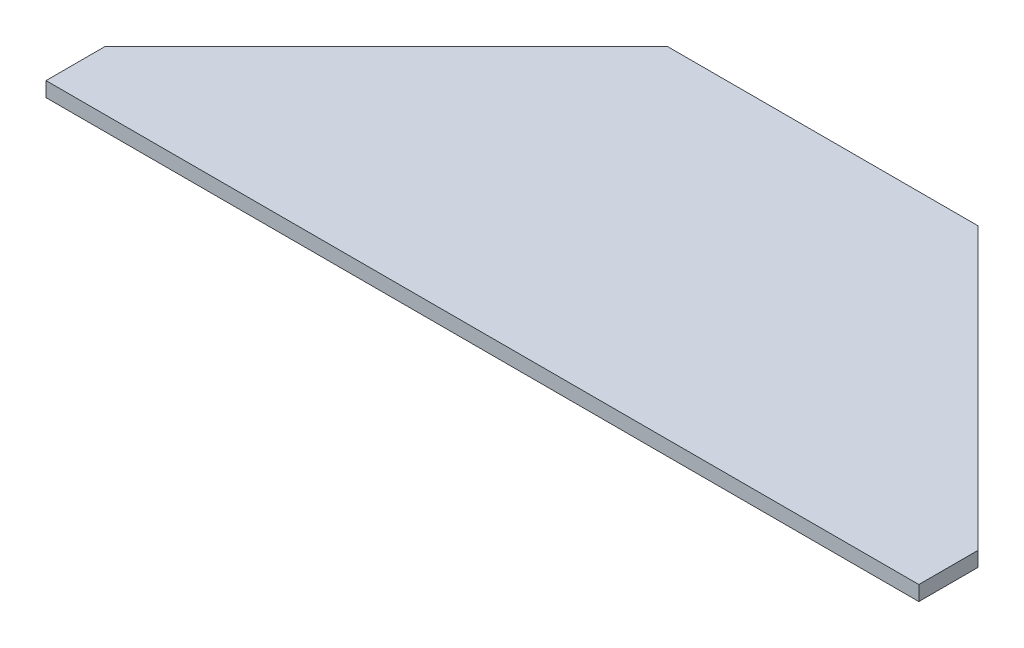
from build123d import *

# Parameters (mm, degrees)
BOSS_EXTRUDE1_DEPTH = 6.35


with BuildPart() as part:
    # Sketch1 → Boss-Extrude1 (new body)
    with BuildSketch(Plane(origin=(0, 0, 0), x_dir=(1, 0, 0), z_dir=(0, 1, 0))):
        Polygon((0, 0), (374.65, 0), (374.65, 25.4), (254, 146.05), (120.65, 146.05), (0, 25.4), align=None)
    extrude(amount=BOSS_EXTRUDE1_DEPTH)


solid = part.part
